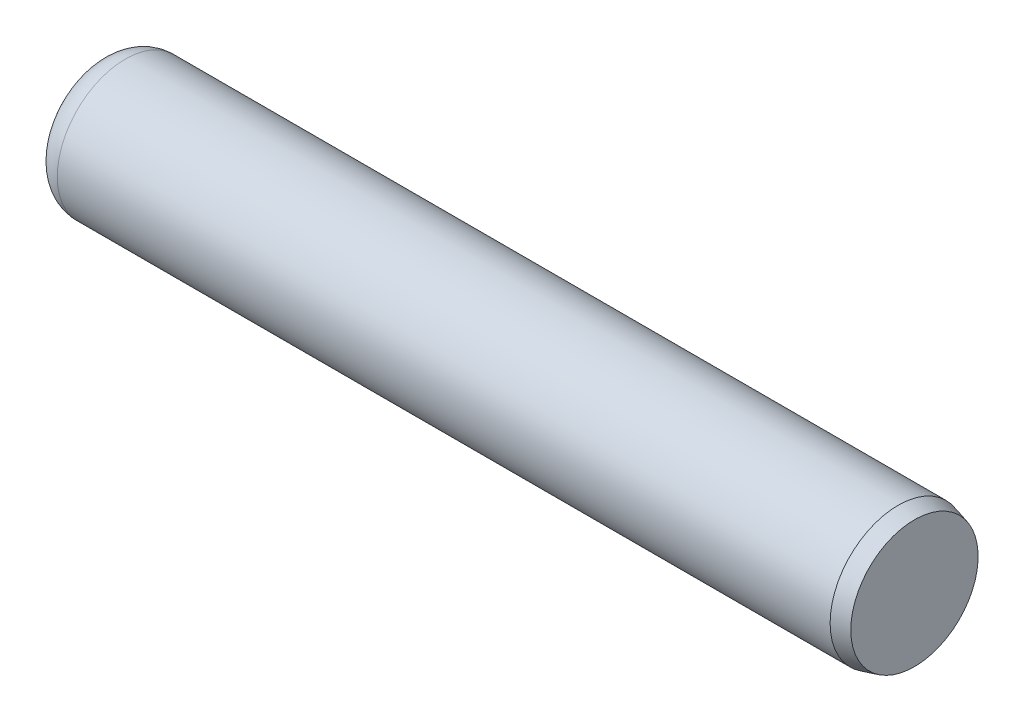
from build123d import *


with BuildPart() as part:
    # Sketch1 → Base-Revolve (revolve)
    with BuildSketch(Plane.XY, mode=Mode.PRIVATE) as base_revolve_sk:
        with BuildLine():
            Line((0, 0), (4.7625, 0))
            Line((4.7625, 0), (4.7625, 0.371352839))
            Line((4.7625, 0.371352839), (4.66725, 0.396875))
            Line((4.66725, 0.396875), (0.15875, 0.396875))
            ThreePointArc((0.15875, 0.396875), (0.046496798, 0.350378202), (0, 0.238125))
            Line((0, 0.238125), (0, 0))
        make_face()
    revolve(base_revolve_sk.sketch.rotate(Axis((-6.35, 0, 0), (1, 0, 0)), 90), axis=Axis((-6.35, 0, 0), (1, 0, 0)))  # turned: the seam where the file's is


solid = part.part
